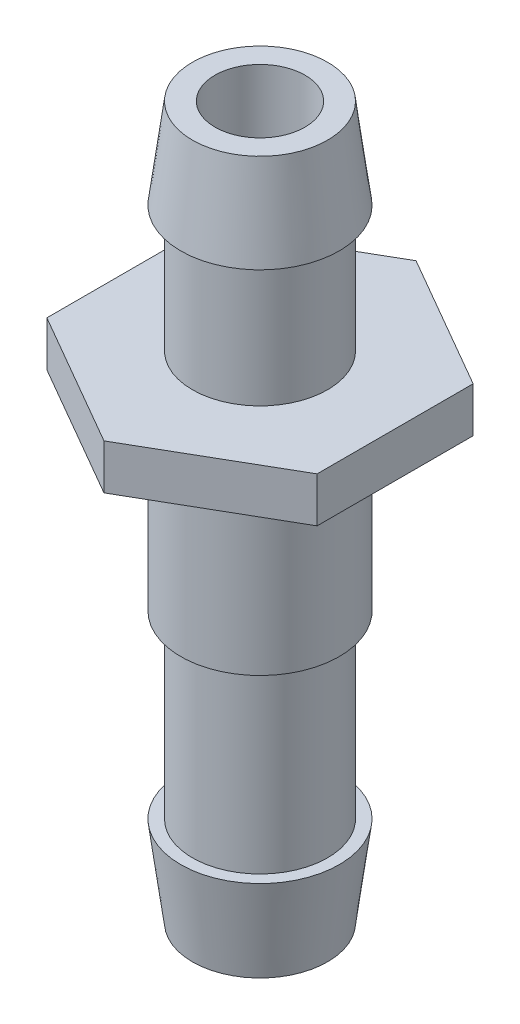
from build123d import *

# Parameters (mm, degrees)
SKETCH1_R          = 4.7625
SKETCH1_R_2        = 3.175
EXTRUDE1_DEPTH     = 15.24
SKETCH2_R          = 3.175
EXTRUDE2_DEPTH     = 3.175
SKETCH3_R          = 4.7625
SKETCH3_R_2        = 3.175
EXTRUDE3_DEPTH     = 31.75
SKETCH4_R          = 7.366
SKETCH4_R_2        = 5.588
CUT_EXTRUDE1_DEPTH = 1.5875
SKETCH5_R          = 5.588
SKETCH5_R_2        = 4.7625
EXTRUDE4_DEPTH     = 6.35
SKETCH8_R          = 5.588
SKETCH8_R_2        = 4.7625
EXTRUDE5_DEPTH     = 6.35
SKETCH9_R          = 5.588
SKETCH9_R_2        = 4.7625
EXTRUDE6_DEPTH     = 12.7


with BuildPart() as part:
    # Sketch1 → Extrude1 (new body)
    with BuildSketch(Plane(origin=(0, 0, 0), x_dir=(1, 0, 0), z_dir=(0, 1, 0))):
        Circle(SKETCH1_R)
        Circle(SKETCH1_R_2, mode=Mode.SUBTRACT)
    extrude(amount=EXTRUDE1_DEPTH)

    # Sketch2 → Extrude2 (add)
    with BuildSketch(Plane.XZ):
        Polygon((9.525, 5.499261314), (9.525, -5.499261314), (0, -10.998522628), (-9.525, -5.499261314), (-9.525, 5.499261314), (0, 10.998522628), align=None)
        Circle(SKETCH2_R, mode=Mode.SUBTRACT)
    extrude(amount=EXTRUDE2_DEPTH)

    # Sketch3 → Extrude3 (add)
    with BuildSketch(Plane.XZ.offset(3.175)):
        Circle(SKETCH3_R)
        Circle(SKETCH3_R_2, mode=Mode.SUBTRACT)
    extrude(amount=EXTRUDE3_DEPTH)

    # Sketch4 → Cut-Extrude1 (cut)
    with BuildSketch(Plane.XZ.offset(3.175)):
        Circle(SKETCH4_R)
        Circle(SKETCH4_R_2, mode=Mode.SUBTRACT)
    extrude(amount=-CUT_EXTRUDE1_DEPTH, mode=Mode.SUBTRACT)

    # Sketch5 → Extrude4 (add)
    with BuildSketch(Plane(origin=(0, 15.24, 0), x_dir=(-1, 0, 0), z_dir=(0, 1, 0))):
        Circle(SKETCH5_R)
        Circle(SKETCH5_R_2, mode=Mode.SUBTRACT)
    extrude(amount=-EXTRUDE4_DEPTH)

    # Sketch8 → Extrude5 (add)
    with BuildSketch(Plane.XZ.offset(34.925)):
        Circle(SKETCH8_R)
        Circle(SKETCH8_R_2, mode=Mode.SUBTRACT)
    extrude(amount=-EXTRUDE5_DEPTH)

    # Sketch7 → Cut-Revolve1 (revolve, cut)
    with BuildSketch(Plane(origin=(0, 0, 0), x_dir=(0, 0, -1), z_dir=(1, 0, 0))):
        Polygon((-5.588, 8.89), (-4.7625, 15.24), (-5.588, 15.24), align=None)
        Polygon((-5.588, -34.925), (-5.588, -28.575), (-4.7625, -34.925), align=None)
    revolve(axis=Axis((0, 15.24, 0), (0, -1, 0)), mode=Mode.SUBTRACT)

    # Sketch9 → Extrude6 (add)
    with BuildSketch(Plane.XZ.offset(3.175)):
        Circle(SKETCH9_R)
        Circle(SKETCH9_R_2, mode=Mode.SUBTRACT)
    extrude(amount=EXTRUDE6_DEPTH)


solid = part.part
